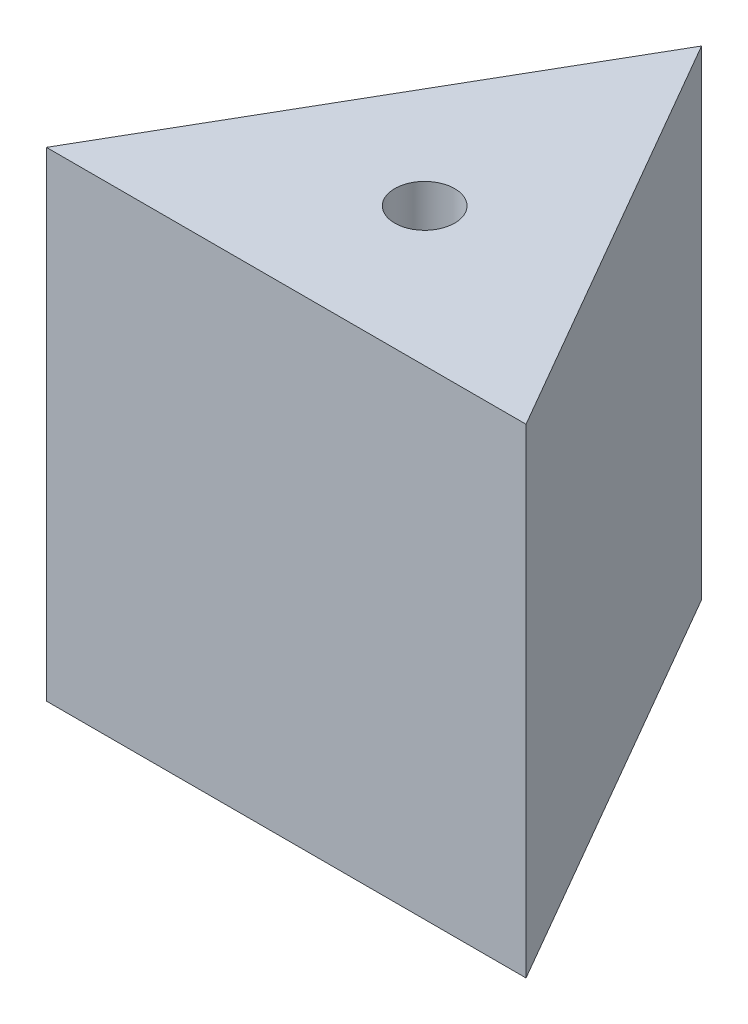
from build123d import *

# Parameters (mm, degrees)
BOSS_EXTRUDE1_DEPTH = 304.8
SKETCH2_R           = 19.05
CUT_EXTRUDE1_DEPTH  = 305.8


with BuildPart() as part:
    # Sketch1 → Boss-Extrude1 (new body)
    with BuildSketch(Plane(origin=(0, 0, 0), x_dir=(1, 0, 0), z_dir=(0, 1, 0))):
        Polygon((0, 0), (-152.4, -263.964543073), (152.4, -263.964543073), align=None)
    extrude(amount=BOSS_EXTRUDE1_DEPTH)

    # Sketch2 → Cut-Extrude1 (cut, through all)
    with BuildSketch(Plane(origin=(0, 304.8, 0), x_dir=(1, 0, 0), z_dir=(0, 1, 0))):
        with Locations((0, -175.976362049)):
            Circle(SKETCH2_R)
    extrude(amount=-CUT_EXTRUDE1_DEPTH, mode=Mode.SUBTRACT)


solid = part.part
